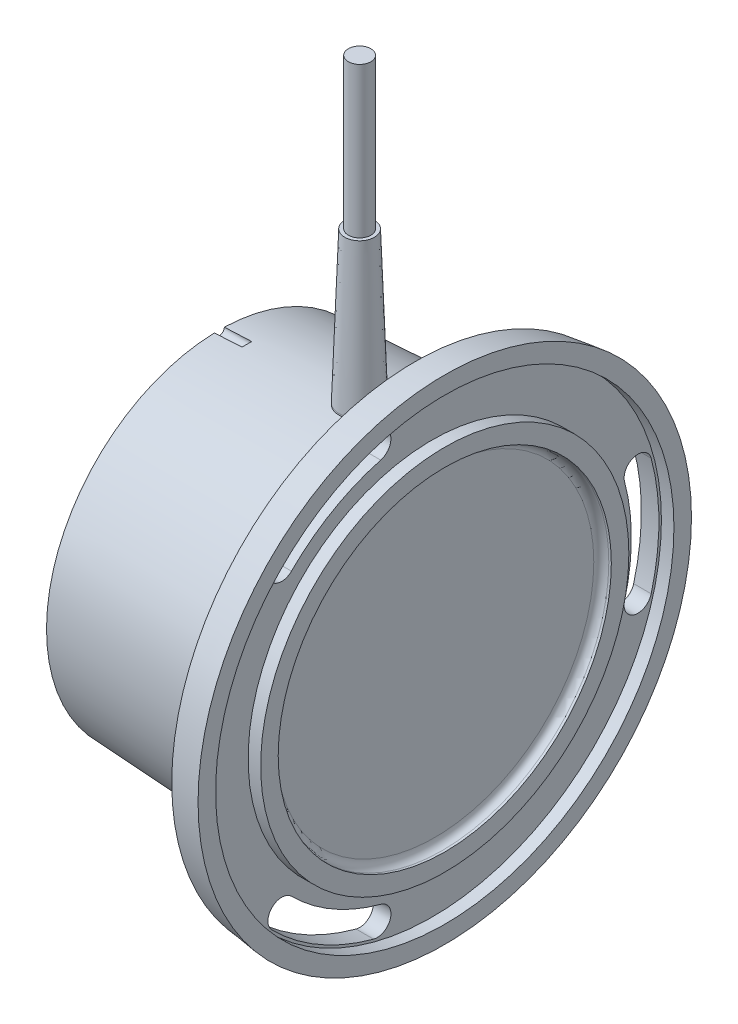
from build123d import *

# Parameters (mm, degrees)
ESQUISSE2_R                  = 1
ENL_V_MAT_EXTRU_1_DEPTH      = 5.5
ESQUISSE3_R                  = 4
EXTRUSION1_DEPTH             = 36
ESQUISSE4_R                  = 4
EXTRUSION2_DEPTH             = 30
EXTRUSION2_TAPER             = 2
ESQUISSE5_R                  = 2.25
EXTRUSION3_DEPTH             = 30
ENL_V_MAT_EXTRU_2_DEPTH      = 115.728211473
R_P_TITION_CIRCULAIRE1_COUNT = 3


with BuildPart() as part:
    # Esquisse1 → Révolution1 (revolve)
    with BuildSketch(Plane.XY):
        with BuildLine():
            Line((0, 0), (0, 34.5))
            Line((0, 34.5), (39, 36.5))
            Line((39, 36.5), (39, 48.5))
            Line((39, 48.5), (45, 49.25))
            Line((45, 49.25), (45, 45.75))
            Line((45, 45.75), (42.5, 45.75))
            Line((42.5, 45.75), (42.5, 36.75))
            Line((42.5, 36.75), (45, 36.75))
            Line((45, 36.75), (45, 33.25))
            Line((45, 33.25), (44.5, 33.25))
            ThreePointArc((44.5, 33.25), (43.439339828, 32.810660172), (43, 31.75))
            Line((43, 31.75), (43, 0))
            Line((43, 0), (0, 0))
        make_face()
    revolve(axis=Axis((104.922362869, 0, 0), (-1, 0, 0)))

    # Esquisse2 → Enlèv. mat.-Extru.1 (cut)
    with BuildSketch(Plane.ZY):
        with Locations((0, 34.5)):
            Circle(ESQUISSE2_R)
    extrude(amount=-ENL_V_MAT_EXTRU_1_DEPTH, mode=Mode.SUBTRACT)

    # Esquisse3 → Extrusion1 (add)
    with BuildSketch(Plane(origin=(0, 0, 0), x_dir=(1, 0, 0), z_dir=(0, 1, 0))):
        with Locations((28, 0)):
            Circle(ESQUISSE3_R)
    extrude(amount=EXTRUSION1_DEPTH)

    # Esquisse4 → Extrusion2 (add)
    with BuildSketch(Plane(origin=(0, 36, 0), x_dir=(-1, 0, 0), z_dir=(0, 1, 0))):
        with Locations((-28, 0)):
            Circle(ESQUISSE4_R)
    extrude(amount=EXTRUSION2_DEPTH, taper=EXTRUSION2_TAPER)

    # Esquisse5 → Extrusion3 (add)
    with BuildSketch(Plane(origin=(0, 66, 0), x_dir=(-1, 0, 0), z_dir=(0, 1, 0))):
        with Locations((-28, 0)):
            Circle(ESQUISSE5_R)
    extrude(amount=EXTRUSION3_DEPTH)

    # Esquisse6 → Enlèv. mat.-Extru.2 (cut, through all)
    with BuildSketch(Plane.ZY.offset(-39)):
        with BuildLine():
            ThreePointArc((-38.395503832, 10.288235294), (-40.340031844, 13.656292718), (-43.708089268, 11.711764706))
            ThreePointArc((-43.708089268, 11.711764706), (-45.25, 0), (-43.708089268, -11.711764706))
            ThreePointArc((-43.708089268, -11.711764706), (-40.340031844, -13.656292718), (-38.395503832, -10.288235294))
            ThreePointArc((-38.395503832, -10.288235294), (-39.75, 0), (-38.395503832, 10.288235294))
        make_face()
    enl_v_mat_extru_2 = extrude(amount=-ENL_V_MAT_EXTRU_2_DEPTH, mode=Mode.SUBTRACT)

    # Répétition circulaire1: Enlèv. mat.-Extru.2 ×3 about axis
    r_p_tition_circulaire1_axis = Axis((39, 0, 0), (-1, 0, 0))
    for i in range(1, R_P_TITION_CIRCULAIRE1_COUNT):
        add(enl_v_mat_extru_2.rotate(r_p_tition_circulaire1_axis, i * 360 / R_P_TITION_CIRCULAIRE1_COUNT), mode=Mode.SUBTRACT)


solid = part.part
